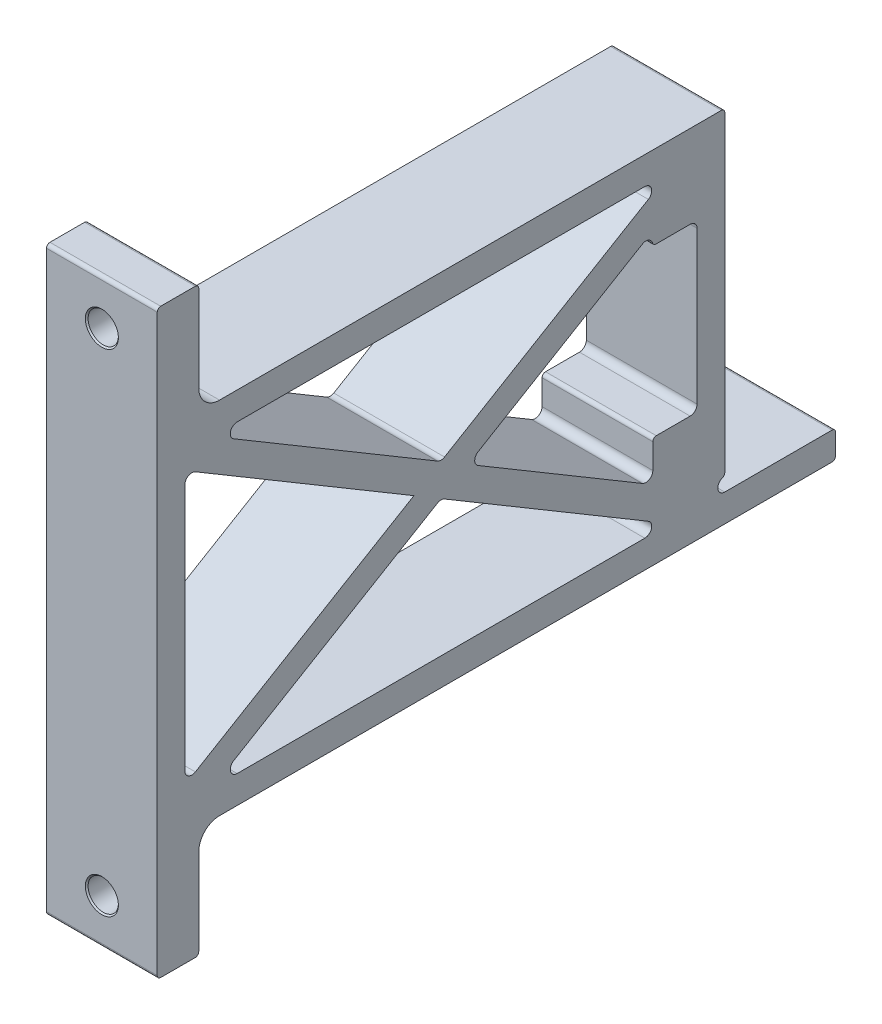
from build123d import *

# Parameters (mm, degrees)
BOSS_EXTRUDE1_DEPTH                          = 25.4
SKETCH2_W                                    = 234.95
SKETCH2_H                                    = 139.7
CUT_EXTRUDE1_DEPTH                           = 51.8
EXTRUDE_THIN1_DEPTH                          = 50.8
EXTRUDE_THIN2_DEPTH                          = 50.8
FILLET5_R                                    = 3.175
SKETCH11_W                                   = 33.02
SKETCH11_H                                   = 38.1
BOSS_EXTRUDE2_DEPTH                          = 50.8
TAPPED_HOLE_FOR_3_8_16_HELICOIL1_D           = 10.0838
TAPPED_HOLE_FOR_3_8_16_HELICOIL1_DEPTH       = 29.21
TAPPED_HOLE_FOR_3_8_16_HELICOIL1_CSINK_D     = 12.95908
TAPPED_HOLE_FOR_3_8_16_HELICOIL1_CSINK_ANGLE = 90
TAPPED_HOLE_FOR_3_8_16_HELICOIL1_TIP         = 3.029479155
CUT_EXTRUDE2_DEPTH                           = 51.8
FILLET1_R                                    = 3.175
FILLET2_R                                    = 1.5875
FILLET3_R                                    = 9.525
F_1_2_CLEARANCE_HOLE1_AT_2_COUNT             = 2
F_1_2_CLEARANCE_HOLE1_AT_2_PITCH             = 225.425


with BuildPart() as part:
    # Sketch1 → Boss-Extrude1 (new body, symmetric)
    with BuildSketch(Plane(origin=(0, 0, 0), x_dir=(0, 0, -1), z_dir=(1, 0, 0))):
        Polygon((311.15, -88.9), (19.05, -88.9), (19.05, -139.7), (0, -139.7), (0, 127), (19.05, 127), (19.05, 76.2), (260.35, 76.2), (260.35, -76.2), (311.15, -76.2), align=None)
    extrude(amount=BOSS_EXTRUDE1_DEPTH, both=True)

    # Sketch2 → Cut-Extrude1 (cut, through all)
    with BuildSketch(Plane.ZY.offset(25.4)):
        with Locations((-130.175, -6.35)):
            Rectangle(SKETCH2_W, SKETCH2_H)
    extrude(amount=-CUT_EXTRUDE1_DEPTH, mode=Mode.SUBTRACT)

    # Sketch3 → Extrude-Thin1 (add)
    with BuildSketch(Plane.ZY.offset(25.4)):
        Polygon((-250.895328745, 58.041947111), (-15.945328745, -81.658052889), (-9.454671255, -70.741947111), (-244.404671255, 68.958052889), align=None)
    extrude(amount=-EXTRUDE_THIN1_DEPTH)

    # Sketch4 → Extrude-Thin2 (add)
    with BuildSketch(Plane.ZY.offset(25.4)):
        Polygon((-244.404671255, -81.658052889), (-9.454671255, 58.041947111), (-15.945328745, 68.958052889), (-250.895328745, -70.741947111), align=None)
    extrude(amount=-EXTRUDE_THIN2_DEPTH)

    # Fillet5
    fillet5_edges = [part.edges().sort_by_distance(p)[0] for p in [
        (0, -76.2, -235.225218669),
        (0, 63.5, -235.225218669),
    ]]
    fillet(fillet5_edges, radius=FILLET5_R)

    # Sketch11 → Boss-Extrude2 (add)
    with BuildSketch(Plane.ZY.offset(25.4)):
        with Locations((-243.84, -57.15)):
            Rectangle(SKETCH11_W, SKETCH11_H)
    boss_extrude2 = extrude(amount=-BOSS_EXTRUDE2_DEPTH)

    # Mirror2: Boss-Extrude2 across plane
    add(boss_extrude2.mirror(Plane.ZX))

    # Tapped Hole for 3/8-16 Helicoil1
    with Locations(Plane(origin=(-14.876894715, 2.702023936, -260.35), x_dir=(-1, 0, 0), z_dir=(0, 0, -1))):
        with Locations((-14.876894715, 54.447976064), (-14.876894715, -59.852023936)):
            CounterSinkHole(TAPPED_HOLE_FOR_3_8_16_HELICOIL1_D / 2, TAPPED_HOLE_FOR_3_8_16_HELICOIL1_CSINK_D / 2, depth=TAPPED_HOLE_FOR_3_8_16_HELICOIL1_DEPTH, counter_sink_angle=TAPPED_HOLE_FOR_3_8_16_HELICOIL1_CSINK_ANGLE)
            with Locations((0, 0, -(TAPPED_HOLE_FOR_3_8_16_HELICOIL1_DEPTH + TAPPED_HOLE_FOR_3_8_16_HELICOIL1_TIP / 2))):  # 118° drill point
                Cone(0, TAPPED_HOLE_FOR_3_8_16_HELICOIL1_D / 2, TAPPED_HOLE_FOR_3_8_16_HELICOIL1_TIP, mode=Mode.SUBTRACT)

    # Sketch12 → Cut-Extrude2 (cut, through all)
    with BuildSketch(Plane.ZY.offset(25.4)):
        with BuildLine():
            Line((-260.35, -76.2), (-260.35, -69.85))
            ThreePointArc((-260.35, -69.85), (-257.175, -73.025), (-260.35, -76.2))
        make_face()
    extrude(amount=-CUT_EXTRUDE2_DEPTH, mode=Mode.SUBTRACT)

    # Fillet1
    fillet1_edges = [part.edges().sort_by_distance(p)[0] for p in [
        (0, -56.73013002, -227.33),
        (0, -38.1, -247.65),
        (0, 44.03013002, -227.33),
        (0, 38.1, -247.65),
        (0, -76.2, -25.124781331),
        (0, -68.812292182, -12.7),
        (0, -6.35, -142.599781331),
        (0, -13.737707818, -130.175),
        (0, 56.112292182, -12.7),
        (0, 63.5, -25.124781331),
        (0, 1.037707818, -130.175),
    ]]
    fillet(fillet1_edges, radius=FILLET1_R)

    # Fillet2
    fillet2_edges = [part.edges().sort_by_distance(p)[0] for p in [
        (0, 127, 0),
        (0, 127, -19.05),
        (0, -139.7, 0),
        (0, -139.7, -19.05),
        (0, -88.9, -311.15),
        (0, -76.2, -311.15),
        (0, 76.2, -260.35),
        (0, 38.1, -227.33),
        (0, -38.1, -227.33),
        (0, -69.85, -260.35),
    ]]
    fillet(fillet2_edges, radius=FILLET2_R)

    # Fillet3
    fillet3_edges = [part.edges().sort_by_distance(p)[0] for p in [
        (0, -88.9, -19.05),
        (0, 76.2, -19.05),
    ]]
    fillet(fillet3_edges, radius=FILLET3_R)

    # Sketch9 → 1/2 Clearance Hole1 (revolve, cut)
    with BuildSketch(Plane(origin=(0, 106.3625, -19.05), x_dir=(0, 1, 0), z_dir=(1, 0, 0))):
        Polygon((0, 0), (0, 19.05), (7.58063, 19.05), (6.94563, 18.415), (6.94563, 0.635), (7.58063, 0), align=None)
    f_1_2_clearance_hole1 = revolve(axis=Axis((0, 106.3625, -25.4), (0, 0, 1)), mode=Mode.SUBTRACT)

    # 1/2 Clearance Hole1 at 2: 1/2 Clearance Hole1 ×2
    with Locations(*[(0, -i * F_1_2_CLEARANCE_HOLE1_AT_2_PITCH, 0) for i in range(1, F_1_2_CLEARANCE_HOLE1_AT_2_COUNT)]):
        add(f_1_2_clearance_hole1, mode=Mode.SUBTRACT)


solid = part.part
